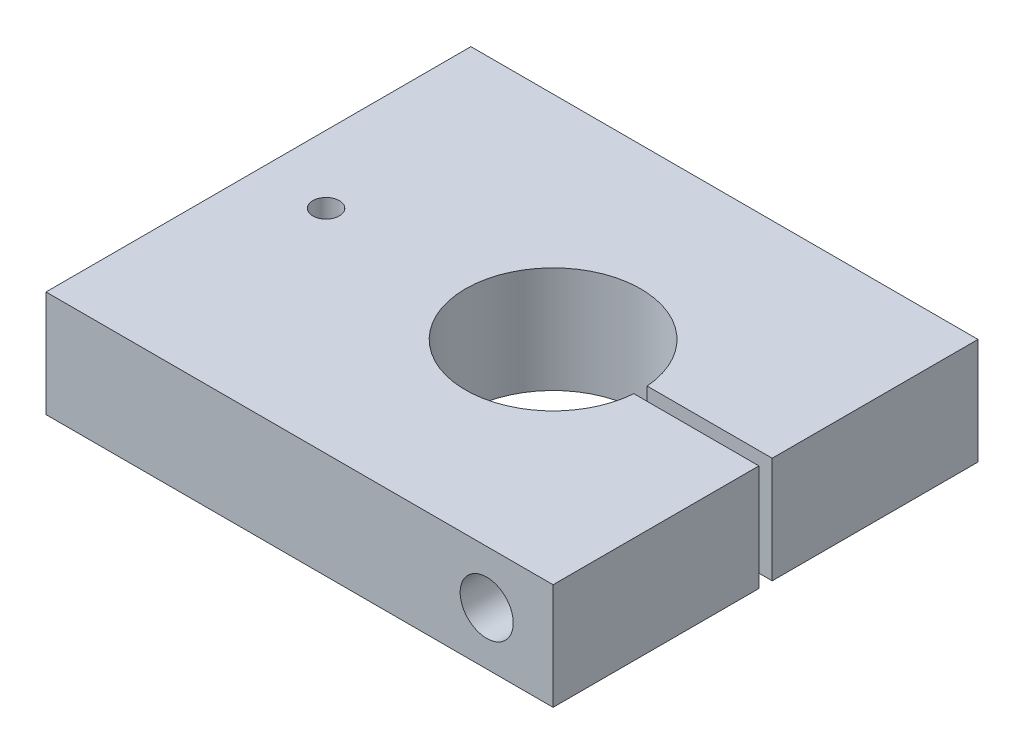
from build123d import *

# Parameters (mm, degrees)
SKETCH1_W           = 121.249023843
SKETCH1_H           = 101.6
SKETCH1_R           = 20.955
SKETCH1_R_2         = 3.175
BOSS_EXTRUDE1_DEPTH = 25.4
SKETCH2_R           = 6.35
CUT_EXTRUDE1_DEPTH  = 102.6
SKETCH3_W           = 31.554427073
SKETCH3_H           = 3.175
CUT_EXTRUDE2_DEPTH  = 26.4


with BuildPart() as part:
    # Sketch1 → Boss-Extrude1 (new body)
    with BuildSketch(Plane(origin=(0, 0, 0), x_dir=(1, 0, 0), z_dir=(0, 1, 0))):
        with Locations((142.575488079, 50.8)):
            Rectangle(SKETCH1_W, SKETCH1_H)
        with Locations((152.4, 50.8)):
            Circle(SKETCH1_R, mode=Mode.SUBTRACT)
        with Locations((98.1075, 50.8)):
            Circle(SKETCH1_R_2, mode=Mode.SUBTRACT)
    extrude(amount=BOSS_EXTRUDE1_DEPTH)

    # Sketch2 → Cut-Extrude1 (cut, through all)
    with BuildSketch(Plane.XY):
        with Locations((187.325, 12.7)):
            Circle(SKETCH2_R)
    extrude(amount=-CUT_EXTRUDE1_DEPTH, mode=Mode.SUBTRACT)

    # Sketch3 → Cut-Extrude2 (cut, through all)
    with BuildSketch(Plane(origin=(0, 25.4, 0), x_dir=(1, 0, 0), z_dir=(0, 1, 0))):
        with Locations((187.422786464, 50.8)):
            Rectangle(SKETCH3_W, SKETCH3_H)
    extrude(amount=-CUT_EXTRUDE2_DEPTH, mode=Mode.SUBTRACT)


solid = part.part
